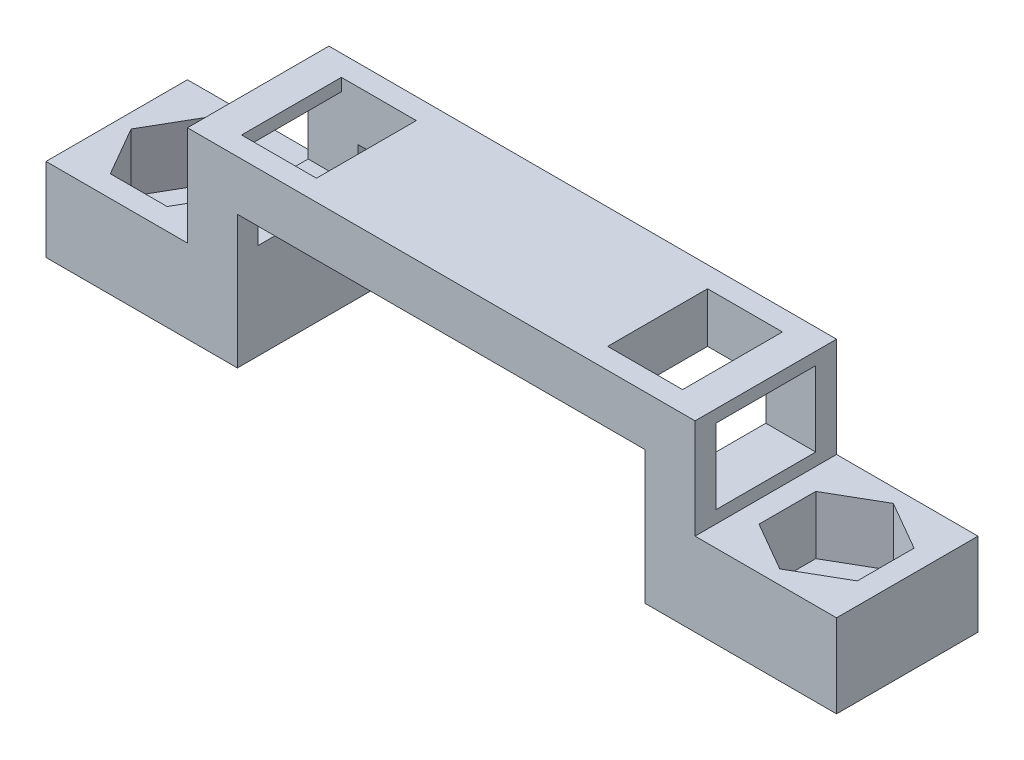
from build123d import *

# Parameters (mm, degrees)
SKETCH1_W           = 8.5
SKETCH1_H           = 8.5
BOSS_EXTRUDE1_DEPTH = 3.5
SKETCH2_W           = 8.5
SKETCH2_H           = 8.5
SKETCH2_R           = 1.5
BOSS_EXTRUDE2_DEPTH = 1.5
SKETCH3_W           = 8.5
SKETCH3_H           = 5
BOSS_EXTRUDE3_DEPTH = 3
SKETCH4_W           = 3
SKETCH4_H           = 8.5
BOSS_EXTRUDE4_DEPTH = 6
SKETCH5_W           = 8.5
SKETCH5_H           = 3
BOSS_EXTRUDE5_DEPTH = 27.5
SKETCH6_W           = 3
SKETCH6_H           = 8.5
BOSS_EXTRUDE6_DEPTH = 8
SKETCH7_W           = 8.5
SKETCH7_H           = 5
BOSS_EXTRUDE7_DEPTH = 8.5
CUT_EXTRUDE1_DEPTH  = 3.5
SKETCH10_R          = 1.5
CUT_EXTRUDE3_DEPTH  = 3.5
SKETCH11_W          = 6
SKETCH11_H          = 4.5
CUT_EXTRUDE4_DEPTH  = 3.5
SKETCH12_W          = 4.5
SKETCH12_H          = 6
CUT_EXTRUDE5_DEPTH  = 3.5
SKETCH13_W          = 6
SKETCH13_H          = 4.5
CUT_EXTRUDE6_DEPTH  = 3.5
SKETCH14_W          = 4.5
SKETCH14_H          = 6
CUT_EXTRUDE7_DEPTH  = 3.5


with BuildPart() as part:
    # Sketch1 → Boss-Extrude1 (new body)
    with BuildSketch(Plane(origin=(0, 0, 0), x_dir=(1, 0, 0), z_dir=(0, 1, 0))):
        with Locations((4.25, 4.25)):
            Rectangle(SKETCH1_W, SKETCH1_H)
        Polygon((5.985496764, 7.195964334), (2.575496764, 7.195964334), (0.870496764, 4.242817707), (2.575496764, 1.28967108), (5.985496764, 1.28967108), (7.690496764, 4.242817707), align=None, mode=Mode.SUBTRACT)
    extrude(amount=BOSS_EXTRUDE1_DEPTH)

    # Sketch2 → Boss-Extrude2 (add)
    with BuildSketch(Plane.XZ):
        with Locations((4.25, -4.25)):
            Rectangle(SKETCH2_W, SKETCH2_H)
        with Locations((4.25, -4.25)):
            Circle(SKETCH2_R, mode=Mode.SUBTRACT)
    extrude(amount=BOSS_EXTRUDE2_DEPTH)

    # Sketch3 → Boss-Extrude3 (add)
    with BuildSketch(Plane(origin=(8.5, 0, 0), x_dir=(0, 0, -1), z_dir=(1, 0, 0))):
        with Locations((4.25, 1)):
            Rectangle(SKETCH3_W, SKETCH3_H)
    extrude(amount=BOSS_EXTRUDE3_DEPTH)

    # Sketch4 → Boss-Extrude4 (add)
    with BuildSketch(Plane(origin=(0, 3.5, 0), x_dir=(1, 0, 0), z_dir=(0, 1, 0))):
        with Locations((10, 4.25)):
            Rectangle(SKETCH4_W, SKETCH4_H)
    extrude(amount=BOSS_EXTRUDE4_DEPTH)

    # Sketch5 → Boss-Extrude5 (add)
    with BuildSketch(Plane(origin=(11.5, 0, 0), x_dir=(0, 0, -1), z_dir=(1, 0, 0))):
        with Locations((4.25, 8)):
            Rectangle(SKETCH5_W, SKETCH5_H)
    extrude(amount=BOSS_EXTRUDE5_DEPTH)

    # Sketch6 → Boss-Extrude6 (add)
    with BuildSketch(Plane.XZ.offset(-6.5)):
        with Locations((37.5, -4.25)):
            Rectangle(SKETCH6_W, SKETCH6_H)
    extrude(amount=BOSS_EXTRUDE6_DEPTH)

    # Sketch7 → Boss-Extrude7 (add)
    with BuildSketch(Plane(origin=(39, 0, 0), x_dir=(0, 0, -1), z_dir=(1, 0, 0))):
        with Locations((4.25, 1)):
            Rectangle(SKETCH7_W, SKETCH7_H)
    extrude(amount=BOSS_EXTRUDE7_DEPTH)

    # Sketch8 → Cut-Extrude1 (cut)
    with BuildSketch(Plane(origin=(0, 3.5, 0), x_dir=(1, 0, 0), z_dir=(0, 1, 0))):
        Polygon((46.203146627, 5.955), (43.25, 7.66), (40.296853373, 5.955), (40.296853373, 2.545), (43.25, 0.84), (46.203146627, 2.545), align=None)
    extrude(amount=-CUT_EXTRUDE1_DEPTH, mode=Mode.SUBTRACT)

    # Sketch10 → Cut-Extrude3 (cut)
    with BuildSketch(Plane(origin=(0, 0, 0), x_dir=(1, 0, 0), z_dir=(0, 1, 0))):
        with Locations((43.25, 4.25)):
            Circle(SKETCH10_R)
    extrude(amount=-CUT_EXTRUDE3_DEPTH, mode=Mode.SUBTRACT)

    # Sketch11 → Cut-Extrude4 (cut)
    with BuildSketch(Plane.ZY.offset(-8.5)):
        with Locations((-4.25, 6.5)):
            Rectangle(SKETCH11_W, SKETCH11_H)
    extrude(amount=-CUT_EXTRUDE4_DEPTH, mode=Mode.SUBTRACT)

    # Sketch12 → Cut-Extrude5 (cut)
    with BuildSketch(Plane(origin=(0, 9.5, 0), x_dir=(1, 0, 0), z_dir=(0, 1, 0))):
        with Locations((12.75, 4.25)):
            Rectangle(SKETCH12_W, SKETCH12_H)
    extrude(amount=-CUT_EXTRUDE5_DEPTH, mode=Mode.SUBTRACT)

    # Sketch13 → Cut-Extrude6 (cut)
    with BuildSketch(Plane(origin=(39, 0, 0), x_dir=(0, 0, -1), z_dir=(1, 0, 0))):
        with Locations((4.25, 6.5)):
            Rectangle(SKETCH13_W, SKETCH13_H)
    extrude(amount=-CUT_EXTRUDE6_DEPTH, mode=Mode.SUBTRACT)

    # Sketch14 → Cut-Extrude7 (cut)
    with BuildSketch(Plane(origin=(0, 9.5, 0), x_dir=(1, 0, 0), z_dir=(0, 1, 0))):
        with Locations((34.75, 4.25)):
            Rectangle(SKETCH14_W, SKETCH14_H)
    extrude(amount=-CUT_EXTRUDE7_DEPTH, mode=Mode.SUBTRACT)


solid = part.part
